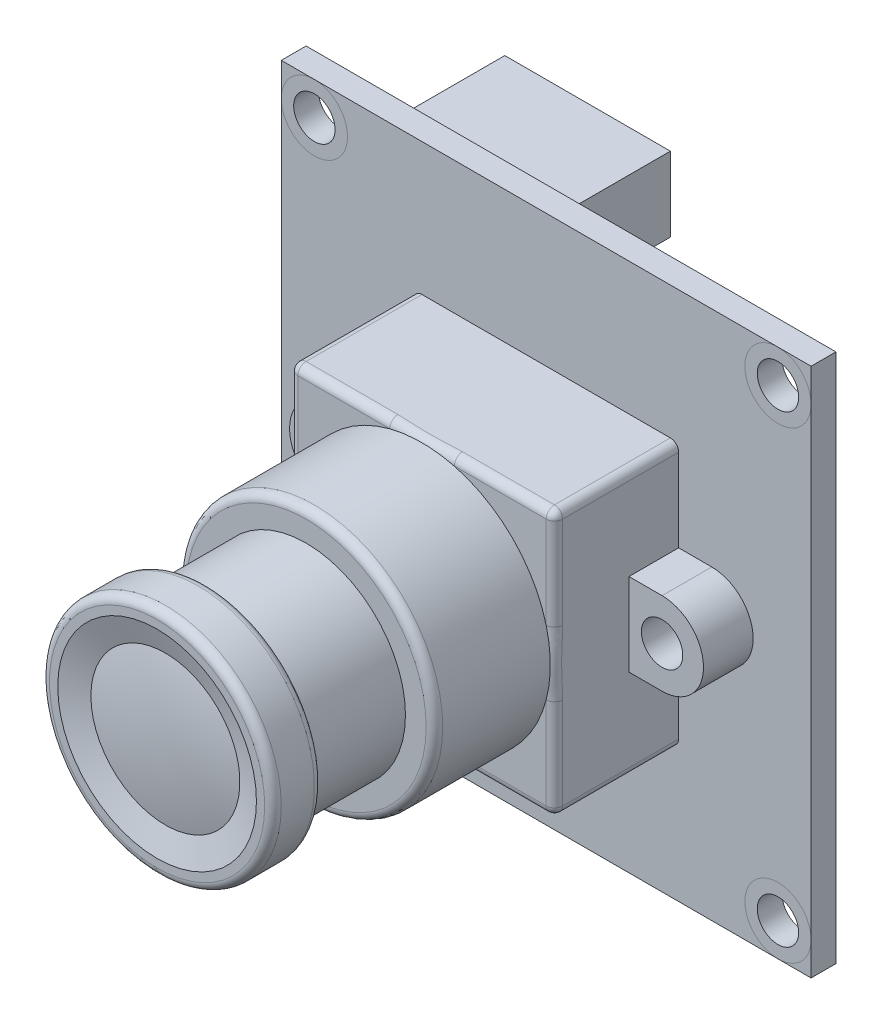
from build123d import *

# Parameters (mm, degrees)
SKETCH1_W           = 32
SKETCH1_H           = 32
BOSS_EXTRUDE1_DEPTH = 1.5
SKETCH2_R           = 1.25
CUT_EXTRUDE1_DEPTH  = 2.5
SKETCH3_W           = 16
SKETCH3_H           = 16
BOSS_EXTRUDE2_DEPTH = 7.5
SKETCH4_R           = 1.25
BOSS_EXTRUDE3_DEPTH = 3
SKETCH5_R           = 7.75
BOSS_EXTRUDE4_DEPTH = 7
SKETCH6_R           = 6
BOSS_EXTRUDE5_DEPTH = 6
SKETCH9_W           = 10
SKETCH9_H           = 4.5
BOSS_EXTRUDE6_DEPTH = 6
FILLET1_R           = 0.5
FILLET2_R           = 0.5


with BuildPart() as part:
    # Sketch1 → Boss-Extrude1 (new body)
    with BuildSketch(Plane.XY):
        Rectangle(SKETCH1_W, SKETCH1_H)
    extrude(amount=BOSS_EXTRUDE1_DEPTH)

    # Sketch2 → Cut-Extrude1 (cut, through all)
    with BuildSketch(Plane.XY.offset(1.5)):
        with Locations((-14, 14)):
            Circle(SKETCH2_R)
        with Locations((14, 14)):
            Circle(SKETCH2_R)
        with Locations((14, -14)):
            Circle(SKETCH2_R)
        with Locations((-14, -14)):
            Circle(SKETCH2_R)
    extrude(amount=-CUT_EXTRUDE1_DEPTH, mode=Mode.SUBTRACT)

    # Sketch3 → Boss-Extrude2 (add)
    with BuildSketch(Plane.XY.offset(1.5)):
        Rectangle(SKETCH3_W, SKETCH3_H)
    extrude(amount=BOSS_EXTRUDE2_DEPTH)

    # Sketch4 → Boss-Extrude3 (add)
    with BuildSketch(Plane.XY.offset(1.5)):
        with BuildLine():
            Line((-10, 2.5), (-8, 2.5))
            Line((-8, 2.5), (-8, -2.5))
            Line((-8, -2.5), (-10, -2.5))
            ThreePointArc((-10, -2.5), (-12.5, 0), (-10, 2.5))
        make_face()
        with Locations((-10, 0)):
            Circle(SKETCH4_R, mode=Mode.SUBTRACT)
        with BuildLine():
            Line((10, -2.5), (8, -2.5))
            Line((8, -2.5), (8, 2.5))
            Line((8, 2.5), (10, 2.5))
            ThreePointArc((10, 2.5), (12.5, 0), (10, -2.5))
        make_face()
        with Locations((10, 0)):
            Circle(SKETCH4_R, mode=Mode.SUBTRACT)
    extrude(amount=BOSS_EXTRUDE3_DEPTH)

    # Sketch5 → Boss-Extrude4 (add)
    with BuildSketch(Plane.XY.offset(9)):
        Circle(SKETCH5_R)
    extrude(amount=BOSS_EXTRUDE4_DEPTH)

    # Sketch6 → Boss-Extrude5 (add)
    with BuildSketch(Plane.XY.offset(16)):
        Circle(SKETCH6_R)
    extrude(amount=BOSS_EXTRUDE5_DEPTH)

    # Sketch8 → Revolve1 (revolve)
    with BuildSketch(Plane(origin=(0, 0, 0), x_dir=(1, 0, 0), z_dir=(0, 1, 0))):
        with BuildLine():
            ThreePointArc((0, -25), (-2.263846285, -24.874616561), (-4.5, -24.5))
            Line((-4.5, -24.5), (-6, -25))
            Line((-6, -25), (-7, -25))
            Line((-7, -25), (-7, -22))
            Line((-7, -22), (0, -22))
            Line((0, -22), (0, -25))
        make_face()
    revolve(axis=Axis((0, 0, 22), (0, 0, 1)))

    # Sketch9 → Boss-Extrude6 (add)
    with BuildSketch(Plane(origin=(0, 0, 0), x_dir=(-1, 0, 0), z_dir=(0, 0, -1))):
        with Locations((5, 13.25)):
            Rectangle(SKETCH9_W, SKETCH9_H)
    extrude(amount=BOSS_EXTRUDE6_DEPTH)

    # Fillet1
    fillet1_edges = [part.edges().sort_by_distance(p)[0] for p in [
        (-8, 8, 5.25),
        (-8, -8, 5.25),
        (8, -8, 5.25),
        (8, 8, 5.25),
    ]]
    fillet(fillet1_edges, radius=FILLET1_R)

    # Fillet2
    fillet2_edges = [part.edges().sort_by_distance(p)[0] for p in [
        (0, -8, 9),
        (-8, 0, 9),
        (8, 0, 9),
        (0, 8, 9),
        (7.853553391, 7.853553391, 9),
        (7.853553391, -7.853553391, 9),
        (-7.853553391, 7.853553391, 9),
        (-7.853553391, -7.853553391, 9),
        (-7.75, 0, 16),
        (7, 0, 22),
        (7, 0, 25),
    ]]
    fillet(fillet2_edges, radius=FILLET2_R)


solid = part.part
